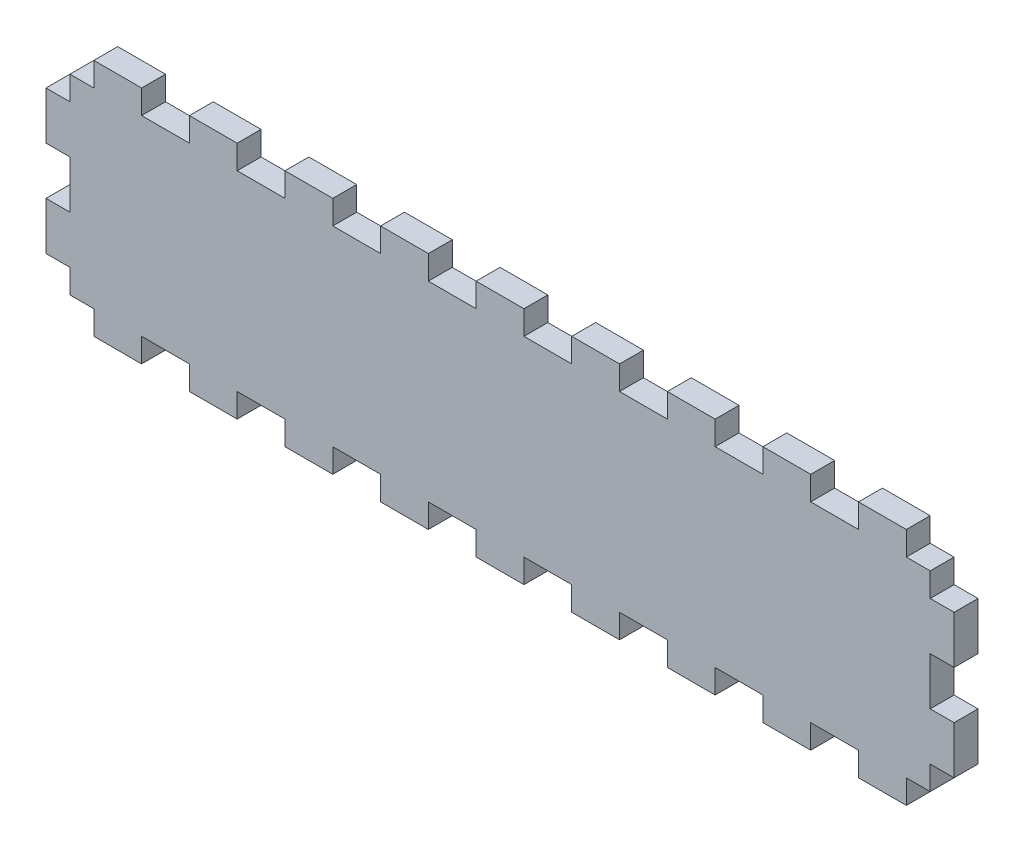
from build123d import *

# Parameters (mm, degrees)
SKETCH2_W           = 241.3
SKETCH2_H           = 63.5
BOSS_EXTRUDE1_DEPTH = 6.35
SKETCH3_W           = 6.35
SKETCH3_H           = 12.7
CUT_EXTRUDE1_DEPTH  = 7.35
LPATTERN1_COUNT     = 3
LPATTERN1_PITCH     = 25.4
SKETCH4_W           = 12.7
SKETCH4_H           = 6.35
CUT_EXTRUDE2_DEPTH  = 7.35
LPATTERN2_COUNT     = 10
LPATTERN2_PITCH     = 25.4


with BuildPart() as part:
    # Sketch2 → Boss-Extrude1 (new body)
    with BuildSketch(Plane.XY):
        with Locations((120.65, 31.75)):
            Rectangle(SKETCH2_W, SKETCH2_H)
    extrude(amount=BOSS_EXTRUDE1_DEPTH)

    # Sketch3 → Cut-Extrude1 (cut, through all)
    with BuildSketch(Plane.XY.offset(6.35)):
        with Locations((3.175, 57.15)):
            Rectangle(SKETCH3_W, SKETCH3_H)
        with Locations((238.125, 57.15)):
            Rectangle(SKETCH3_W, SKETCH3_H)
    cut_extrude1 = extrude(amount=-CUT_EXTRUDE1_DEPTH, mode=Mode.SUBTRACT)

    # LPattern1: Cut-Extrude1 ×3
    with Locations(*[(0, -i * LPATTERN1_PITCH, 0) for i in range(1, LPATTERN1_COUNT)]):
        add(cut_extrude1, mode=Mode.SUBTRACT)

    # Sketch4 → Cut-Extrude2 (cut, through all)
    with BuildSketch(Plane.XY.offset(6.35)):
        with Locations((6.35, 60.325)):
            Rectangle(SKETCH4_W, SKETCH4_H)
        with Locations((6.35, 3.175)):
            Rectangle(SKETCH4_W, SKETCH4_H)
    cut_extrude2 = extrude(amount=-CUT_EXTRUDE2_DEPTH, mode=Mode.SUBTRACT)

    # LPattern2: Cut-Extrude2 ×10
    with Locations(*[(i * LPATTERN2_PITCH, 0, 0) for i in range(1, LPATTERN2_COUNT)]):
        add(cut_extrude2, mode=Mode.SUBTRACT)


solid = part.part
